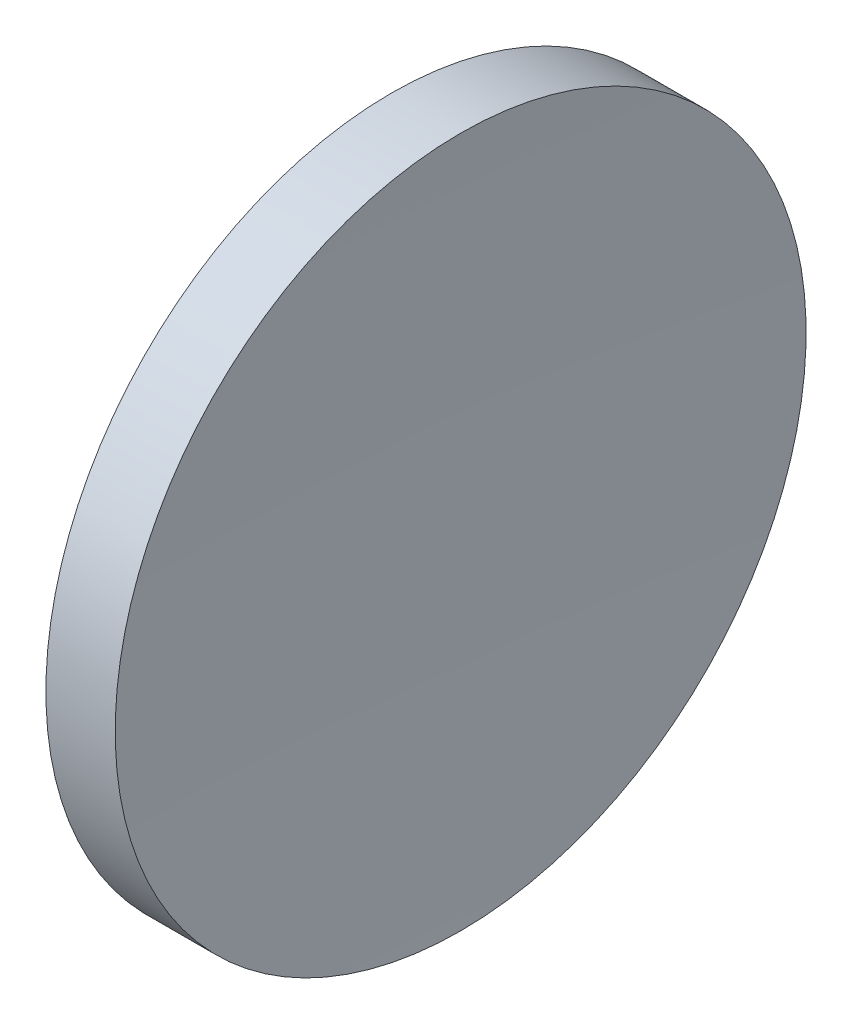
from build123d import *


with BuildPart() as part:
    # 草图1 → 旋转1 (revolve)
    with BuildSketch(Plane.XY, mode=Mode.PRIVATE) as revolve_1_sk:
        with BuildLine():
            Line((97.090444348, 52.178082298), (95.090443589, 52.178082298))
            ThreePointArc((95.090443589, 52.178082298), (95.02501947, 58.529632211), (94.816098176, 64.878082298))
            Line((94.816098176, 64.878082298), (96.090443968, 64.878082298))
            Line((96.090443968, 64.878082298), (97.36478976, 64.878082298))
            ThreePointArc((97.36478976, 64.878082298), (97.155868466, 58.529632211), (97.090444348, 52.178082298))
        make_face()
    revolve(revolve_1_sk.sketch.rotate(Axis((89.858656454, 52.178082298, 0), (1, 0, 0)), 180), axis=Axis((89.858656454, 52.178082298, 0), (1, 0, 0)))  # turned: the seam where the file's is


solid = part.part
